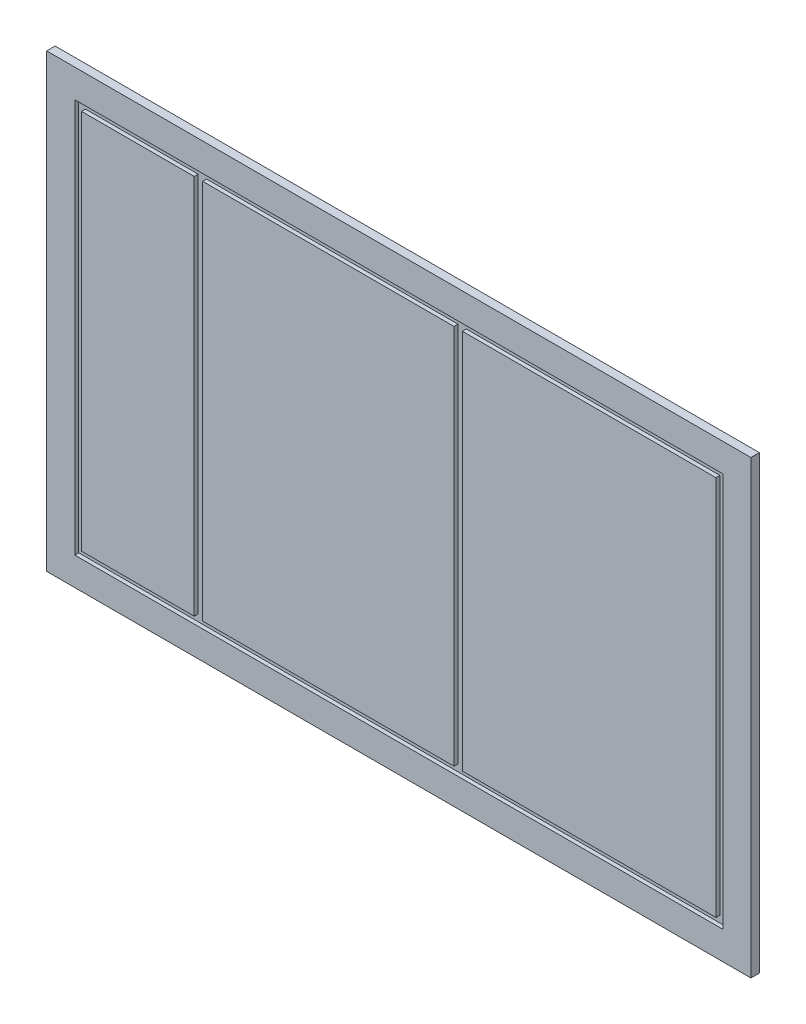
from build123d import *

# Parameters (mm, degrees)
ESQUISSE1_W             = 1250
ESQUISSE1_H             = 800
BOSS_EXTRU_1_DEPTH      = 15
ESQUISSE2_W             = 1150
ESQUISSE2_H             = 700
ESQUISSE2_W_2           = 1126
ESQUISSE2_H_2           = 676
ENL_V_MAT_EXTRU_1_DEPTH = 7
ESQUISSE4_W             = 15
ESQUISSE4_H             = 676
ENL_V_MAT_EXTRU_2_DEPTH = 7


with BuildPart() as part:
    # Esquisse1 → Boss.-Extru.1 (new body)
    with BuildSketch(Plane.XY):
        Rectangle(ESQUISSE1_W, ESQUISSE1_H)
    extrude(amount=BOSS_EXTRU_1_DEPTH)

    # Esquisse2 → Enlèv. mat.-Extru.1 (cut)
    with BuildSketch(Plane.XY.offset(15)):
        Rectangle(ESQUISSE2_W, ESQUISSE2_H)
        Rectangle(ESQUISSE2_W_2, ESQUISSE2_H_2, mode=Mode.SUBTRACT)
    extrude(amount=-ENL_V_MAT_EXTRU_1_DEPTH, mode=Mode.SUBTRACT)

    # Esquisse4 → Enlèv. mat.-Extru.2 (cut)
    with BuildSketch(Plane.XY.offset(15)):
        with Locations((-355.5, 0)):
            Rectangle(ESQUISSE4_W, ESQUISSE4_H)
        with Locations((105.5, 0)):
            Rectangle(ESQUISSE4_W, ESQUISSE4_H)
    extrude(amount=-ENL_V_MAT_EXTRU_2_DEPTH, mode=Mode.SUBTRACT)


solid = part.part
